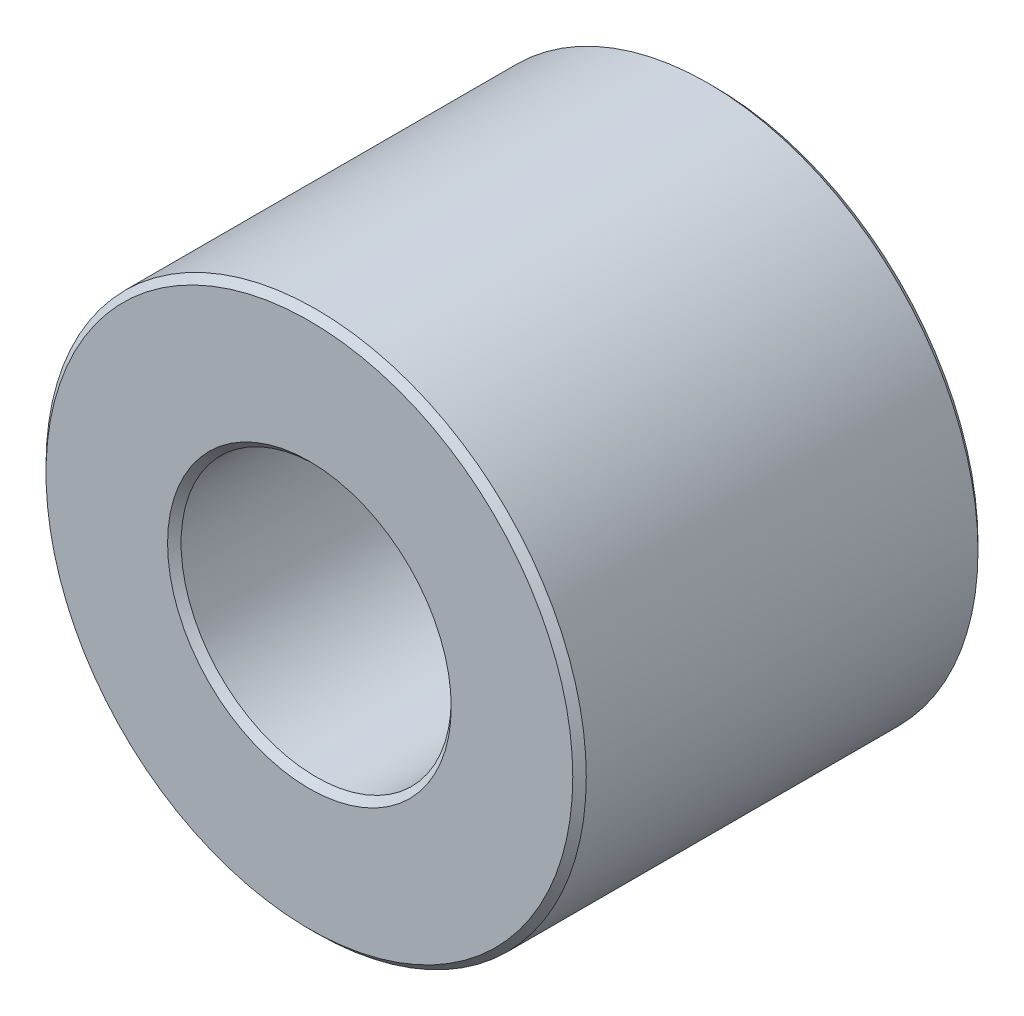
from build123d import *

# Parameters (mm, degrees)
CROQUIS1_R              = 4
CROQUIS1_R_2            = 2
SALIENTE_EXTRUIR1_DEPTH = 6
CHAFL_N1_SIZE           = 0.1


with BuildPart() as part:
    # Croquis1 → Saliente-Extruir1 (new body)
    with BuildSketch(Plane.XY):
        Circle(CROQUIS1_R)
        Circle(CROQUIS1_R_2, mode=Mode.SUBTRACT)
    extrude(amount=SALIENTE_EXTRUIR1_DEPTH)

    # Chaflán1
    chafl_n1_edges = [part.edges().sort_by_distance(p)[0] for p in [
        (-4, 0, 0),
        (-4, 0, 6),
        (-2, 0, 0),
        (-2, 0, 6),
    ]]
    chamfer(chafl_n1_edges, length=CHAFL_N1_SIZE)


solid = part.part
